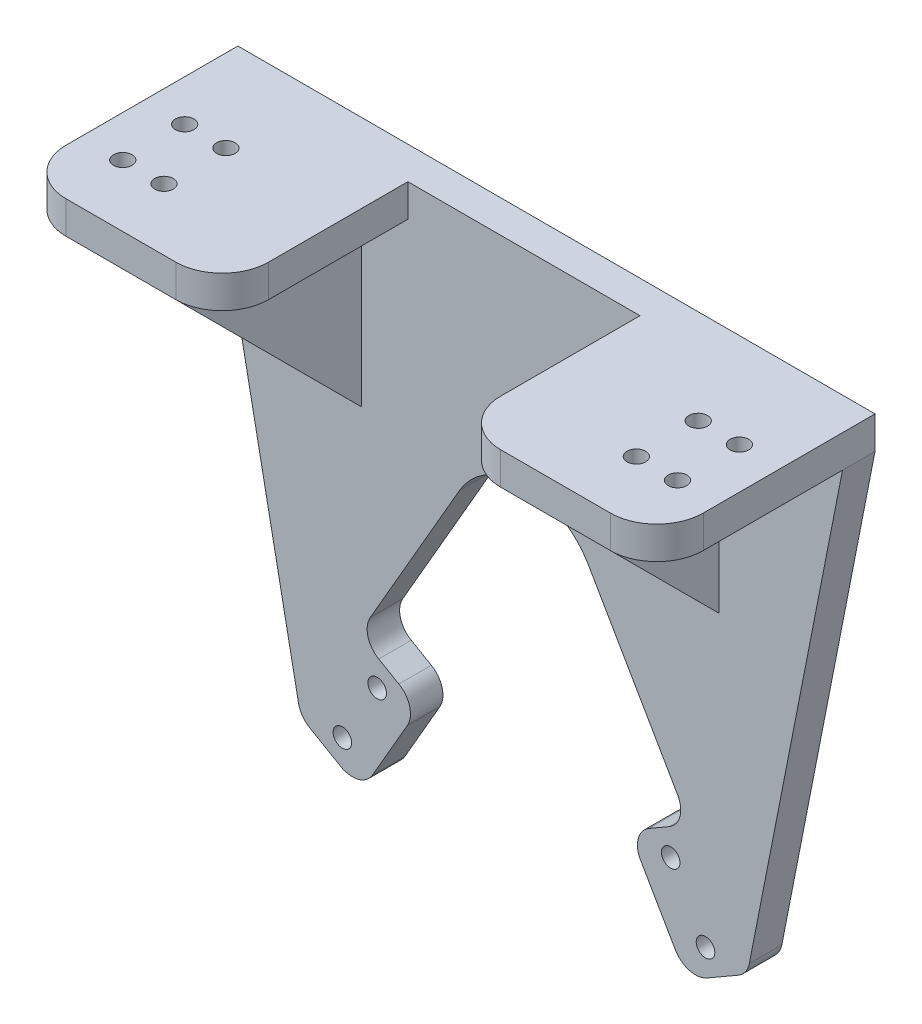
from build123d import *

# Parameters (mm, degrees)
BOSS_EXTRUDE1_DEPTH = 7
SKETCH5_R           = 2
CUT_EXTRUDE2_DEPTH  = 8
BOSS_EXTRUDE2_DEPTH = 40
CUT_EXTRUDE3_DEPTH  = 48
BOSS_EXTRUDE3_DEPTH = 7
BOSS_EXTRUDE4_DEPTH = 7
FILLET1_R           = 5
SKETCH10_W          = 50
SKETCH10_H          = 40
CUT_EXTRUDE4_DEPTH  = 117.99261314
FILLET2_R           = 10
SKETCH11_R          = 2
CUT_EXTRUDE5_DEPTH  = 8


with BuildPart() as part:
    # Sketch4 → Boss-Extrude1 (new body)
    with BuildSketch(Plane.XY):
        with BuildLine():
            Line((-13.856406461, 8), (-35.606406461, -29.672105065))
            Line((-35.606406461, -29.672105065), (-22.616025404, -37.172105065))
            Line((-22.616025404, -37.172105065), (-35.116025404, -58.822740159))
            Line((-35.116025404, -58.822740159), (-48.106406461, -51.322740159))
            Line((-48.106406461, -51.322740159), (-70, 60))
            Line((-70, 60), (70, 60))
            Line((70, 60), (48.106406461, -51.322740159))
            Line((48.106406461, -51.322740159), (35.116025404, -58.822740159))
            Line((35.116025404, -58.822740159), (22.616025404, -37.172105065))
            Line((22.616025404, -37.172105065), (35.606406461, -29.672105065))
            Line((35.606406461, -29.672105065), (13.856406461, 8))
            ThreePointArc((13.856406461, 8), (0, 16), (-13.856406461, 8))
        make_face()
    extrude(amount=BOSS_EXTRUDE1_DEPTH)

    # Sketch5 → Cut-Extrude2 (cut, through all)
    with BuildSketch(Plane.XY):
        with Locations((-39.11, -50.743315159)):
            Circle(SKETCH5_R)
        with Locations((-31.61, -37.752934102)):
            Circle(SKETCH5_R)
        with Locations((39.11, -50.743315159)):
            Circle(SKETCH5_R)
        with Locations((31.61, -37.752934102)):
            Circle(SKETCH5_R)
    extrude(amount=CUT_EXTRUDE2_DEPTH, mode=Mode.SUBTRACT)

    # Sketch6 → Boss-Extrude2 (add)
    with BuildSketch(Plane.XY.offset(7)):
        Polygon((-68.623325705, 53), (68.623325705, 53), (70, 60), (-70, 60), align=None)
    extrude(amount=BOSS_EXTRUDE2_DEPTH)

    # Sketch7 → Cut-Extrude3 (cut, through all)
    with BuildSketch(Plane.XY.offset(47)):
        Polygon((-68.623325705, 53), (-68.623325705, 60), (-70, 60), align=None)
        Polygon((68.623325705, 53), (68.623325705, 60), (70, 60), align=None)
    extrude(amount=-CUT_EXTRUDE3_DEPTH, mode=Mode.SUBTRACT)

    # Sketch8 → Boss-Extrude3 (add)
    with BuildSketch(Plane.ZY.offset(35)):
        Polygon((7, 13), (47, 53), (7, 53), align=None)
    extrude(amount=BOSS_EXTRUDE3_DEPTH)

    # Sketch9 → Boss-Extrude4 (add)
    with BuildSketch(Plane(origin=(35, 0, 0), x_dir=(0, 0, -1), z_dir=(1, 0, 0))):
        Polygon((-7, 13), (-47, 53), (-7, 53), align=None)
    extrude(amount=BOSS_EXTRUDE4_DEPTH)

    # Fillet1
    fillet1_edges = [part.edges().sort_by_distance(p)[0] for p in [
        (-35.606406461, -29.672105065, 3.5),
        (-22.616025404, -37.172105065, 3.5),
        (-35.116025404, -58.822740159, 3.5),
        (-48.106406461, -51.322740159, 3.5),
        (48.106406461, -51.322740159, 3.5),
        (35.116025404, -58.822740159, 3.5),
        (22.616025404, -37.172105065, 3.5),
        (35.606406461, -29.672105065, 3.5),
    ]]
    fillet(fillet1_edges, radius=FILLET1_R)

    # Sketch10 → Cut-Extrude4 (cut, through all)
    with BuildSketch(Plane(origin=(0, 60, 0), x_dir=(1, 0, 0), z_dir=(0, 1, 0))):
        with Locations((0, -27)):
            Rectangle(SKETCH10_W, SKETCH10_H)
    extrude(amount=-CUT_EXTRUDE4_DEPTH, mode=Mode.SUBTRACT)

    # Fillet2
    fillet2_edges = [part.edges().sort_by_distance(p)[0] for p in [
        (25, 56.5, 47),
        (-25, 56.5, 47),
        (-68.623325705, 56.5, 47),
        (68.623325705, 56.5, 47),
    ]]
    fillet(fillet2_edges, radius=FILLET2_R)

    # Sketch11 → Cut-Extrude5 (cut, through all)
    with BuildSketch(Plane.XZ.offset(-53)):
        with Locations((-59.748883804, 33.666666667)):
            Circle(SKETCH11_R)
        with Locations((-50.874441902, 33.666666667)):
            Circle(SKETCH11_R)
        with Locations((-59.748883804, 20.333333333)):
            Circle(SKETCH11_R)
        with Locations((-50.874441902, 20.333333333)):
            Circle(SKETCH11_R)
        with Locations((50.874441902, 20.333333333)):
            Circle(SKETCH11_R)
        with Locations((59.748883804, 20.333333333)):
            Circle(SKETCH11_R)
        with Locations((50.874441902, 33.666666667)):
            Circle(SKETCH11_R)
        with Locations((59.748883804, 33.666666667)):
            Circle(SKETCH11_R)
    extrude(amount=-CUT_EXTRUDE5_DEPTH, mode=Mode.SUBTRACT)


solid = part.part
